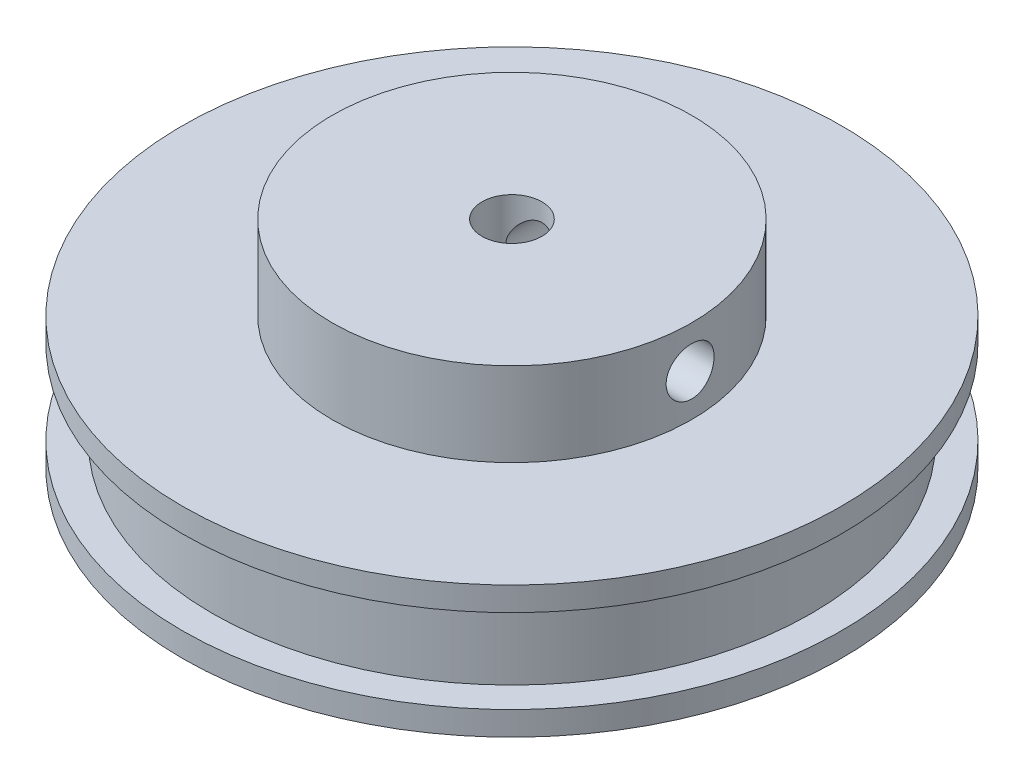
from build123d import *

# Parameters (mm, degrees)
SKETCH1_R           = 27.5
BOSS_EXTRUDE1_DEPTH = 2
SKETCH2_R           = 25
BOSS_EXTRUDE2_DEPTH = 7
SKETCH3_R           = 27.5
BOSS_EXTRUDE3_DEPTH = 2
SKETCH4_R           = 15
BOSS_EXTRUDE4_DEPTH = 7
SKETCH5_R           = 2.5
CUT_EXTRUDE1_DEPTH  = 19
SKETCH6_R           = 2
CUT_EXTRUDE2_DEPTH  = 28.5
CIRPATTERN1_COUNT   = 2
CIRPATTERN1_ANGLE   = 90


with BuildPart() as part:
    # Sketch1 → Boss-Extrude1 (new body)
    with BuildSketch(Plane(origin=(0, 0, 0), x_dir=(1, 0, 0), z_dir=(0, 1, 0))):
        Circle(SKETCH1_R)
    extrude(amount=BOSS_EXTRUDE1_DEPTH)

    # Sketch2 → Boss-Extrude2 (add)
    with BuildSketch(Plane(origin=(0, 2, 0), x_dir=(1, 0, 0), z_dir=(0, 1, 0))):
        Circle(SKETCH2_R)
    extrude(amount=BOSS_EXTRUDE2_DEPTH)

    # Sketch3 → Boss-Extrude3 (add)
    with BuildSketch(Plane(origin=(0, 9, 0), x_dir=(1, 0, 0), z_dir=(0, 1, 0))):
        Circle(SKETCH3_R)
    extrude(amount=BOSS_EXTRUDE3_DEPTH)

    # Sketch4 → Boss-Extrude4 (add)
    with BuildSketch(Plane(origin=(0, 11, 0), x_dir=(1, 0, 0), z_dir=(0, 1, 0))):
        Circle(SKETCH4_R)
    extrude(amount=BOSS_EXTRUDE4_DEPTH)

    # Sketch5 → Cut-Extrude1 (cut, through all)
    with BuildSketch(Plane(origin=(0, 18, 0), x_dir=(1, 0, 0), z_dir=(0, 1, 0))):
        Circle(SKETCH5_R)
    extrude(amount=-CUT_EXTRUDE1_DEPTH, mode=Mode.SUBTRACT)

    # Sketch6 → Cut-Extrude2 (cut, through all)
    with BuildSketch(Plane.XY):
        with Locations((0, 14.5)):
            Circle(SKETCH6_R)
    cut_extrude2 = extrude(amount=-CUT_EXTRUDE2_DEPTH, mode=Mode.SUBTRACT)

    # CirPattern1: Cut-Extrude2 ×2 about axis
    cirpattern1_axis = Axis((0, 18, 0), (0, -1, 0))
    for i in range(1, CIRPATTERN1_COUNT):
        add(cut_extrude2.rotate(cirpattern1_axis, i * CIRPATTERN1_ANGLE / (CIRPATTERN1_COUNT - 1)), mode=Mode.SUBTRACT)


solid = part.part
